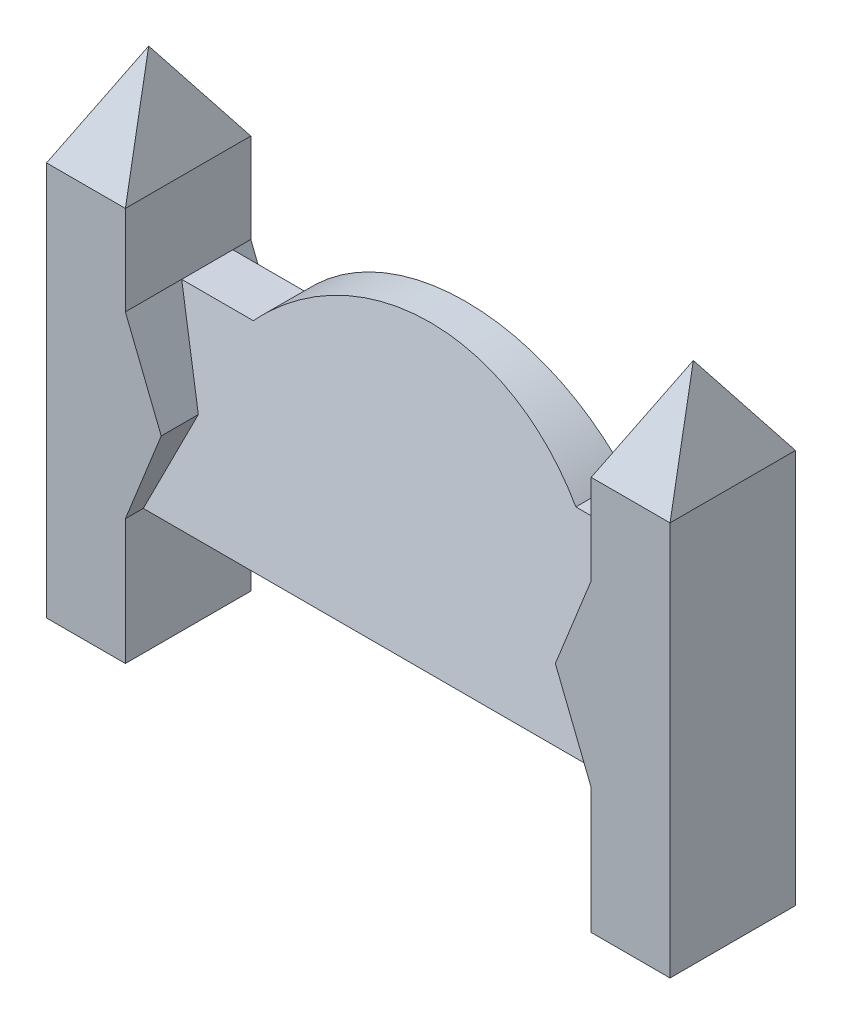
from build123d import *

# Parameters (mm, degrees)
EXTRUDE1_DEPTH     = 350
EXTRUDE1_2_DEPTH   = 350
EXTRUDE2_START     = -220
EXTRUDE2_DEPTH     = 1300
SKETCH3_W          = 220
SKETCH3_H          = 350
SKETCH4_W          = 220
SKETCH4_H          = 350
CUT_EXTRUDE1_DEPTH = 351.0000001


with BuildPart() as part:
    # Sketch1 → Extrude1 (new body)
    with BuildSketch(Plane.XY):
        Polygon((220, 850), (220, 1100), (0, 1100), (0, 0), (220, 0), (220, 350), (320, 600), align=None)
    extrude(amount=EXTRUDE1_DEPTH)



with BuildPart() as body_2:
    # Sketch1 → Extrude1 2 (new body)
    with BuildSketch(Plane.XY):
        Polygon((1740, 0), (1520, 0), (1520, 350), (1420, 600), (1520, 850), (1520, 1100), (1740, 1100), align=None)
    extrude(amount=EXTRUDE1_2_DEPTH)


with BuildPart() as part_1:
    add(part.part)

    add(body_2.part)  # Extrude2 merges body 2
    # Sketch2 → Extrude2 (add)
    with BuildSketch(Plane.ZY.offset(EXTRUDE2_START)):
        Polygon((50, 1050), (150, 1050), (300, 350), (50, 350), align=None)
    extrude(amount=-EXTRUDE2_DEPTH)

    # Sketch3 → Loft1 section 0
    with BuildSketch(Plane(origin=(0, 1100, 0), x_dir=(-1, 0, 0), z_dir=(0, 1, 0)), mode=Mode.PRIVATE) as loft1_s0:
        with Locations((-110, 175)):
            Rectangle(SKETCH3_W, SKETCH3_H)
    loft([loft1_s0.sketch, Vertex(110, 1350, 175)])

    # Sketch4 → Loft2 section 0
    with BuildSketch(Plane(origin=(0, 1100, 0), x_dir=(-1, 0, 0), z_dir=(0, 1, 0)), mode=Mode.PRIVATE) as loft2_s0:
        with Locations((-1630, 175)):
            Rectangle(SKETCH4_W, SKETCH4_H)
    loft([Vertex(1630, 1350, 175), loft2_s0.sketch])

    # Sketch7 → Cut-Extrude1 (cut, through all)
    with BuildSketch(Plane.XY):
        with BuildLine():
            Line((1520, 850), (1520, 1176.43317984))
            Line((1520, 1176.43317984), (220, 1176.43317984))
            Line((220, 1176.43317984), (220, 850))
            Line((220, 850), (420, 850))
            ThreePointArc((420, 850), (870, 1050), (1320, 850))
            Line((1320, 850), (1520, 850))
        make_face()
    extrude(amount=CUT_EXTRUDE1_DEPTH, mode=Mode.SUBTRACT)


solid = part_1.part
